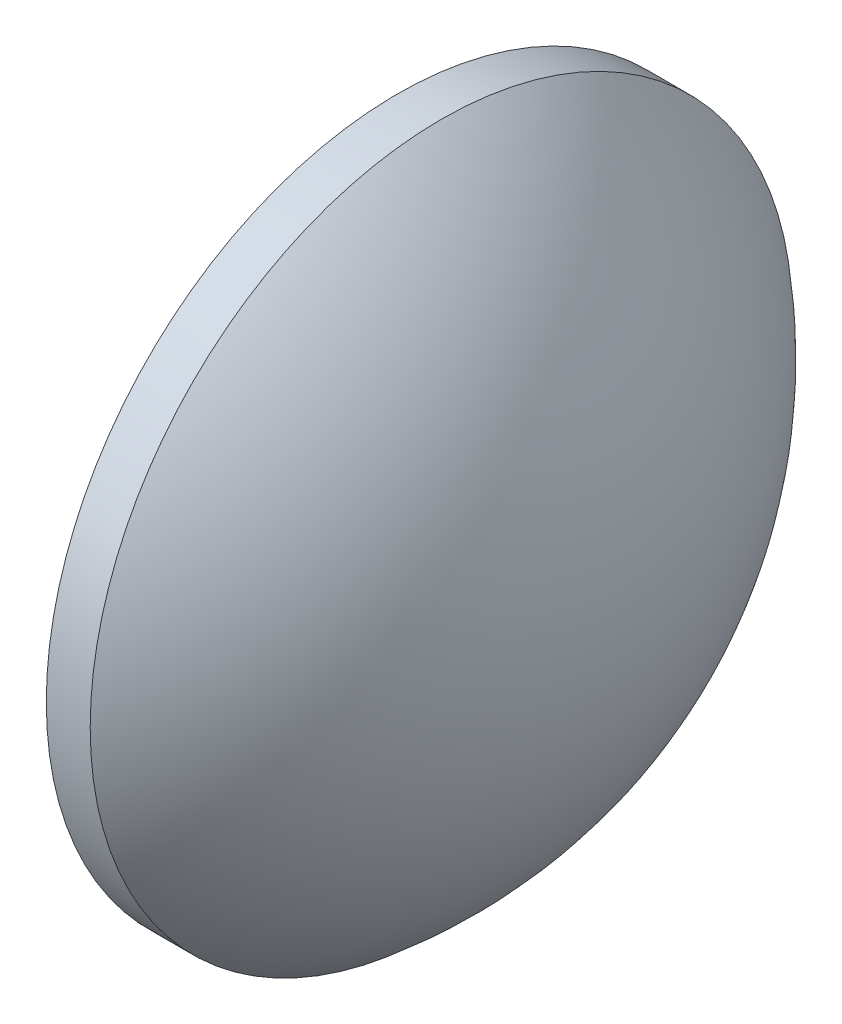
from build123d import *


with BuildPart() as part:
    # 草图1 → 旋转1 (revolve)
    with BuildSketch(Plane.XY):
        with BuildLine():
            Line((113.360117511, 65.02094538), (113.360117511, 85.02094538))
            Line((113.360117511, 85.02094538), (115.860117511, 85.02094538))
            ThreePointArc((115.860117511, 85.02094538), (122.850134454, 76.087453411), (125.340117511, 65.02094538))
            Line((125.340117511, 65.02094538), (113.360117511, 65.02094538))
        make_face()
    revolve(axis=Axis((108.66557433, 65.02094538, 0), (1, 0, 0)))


solid = part.part
